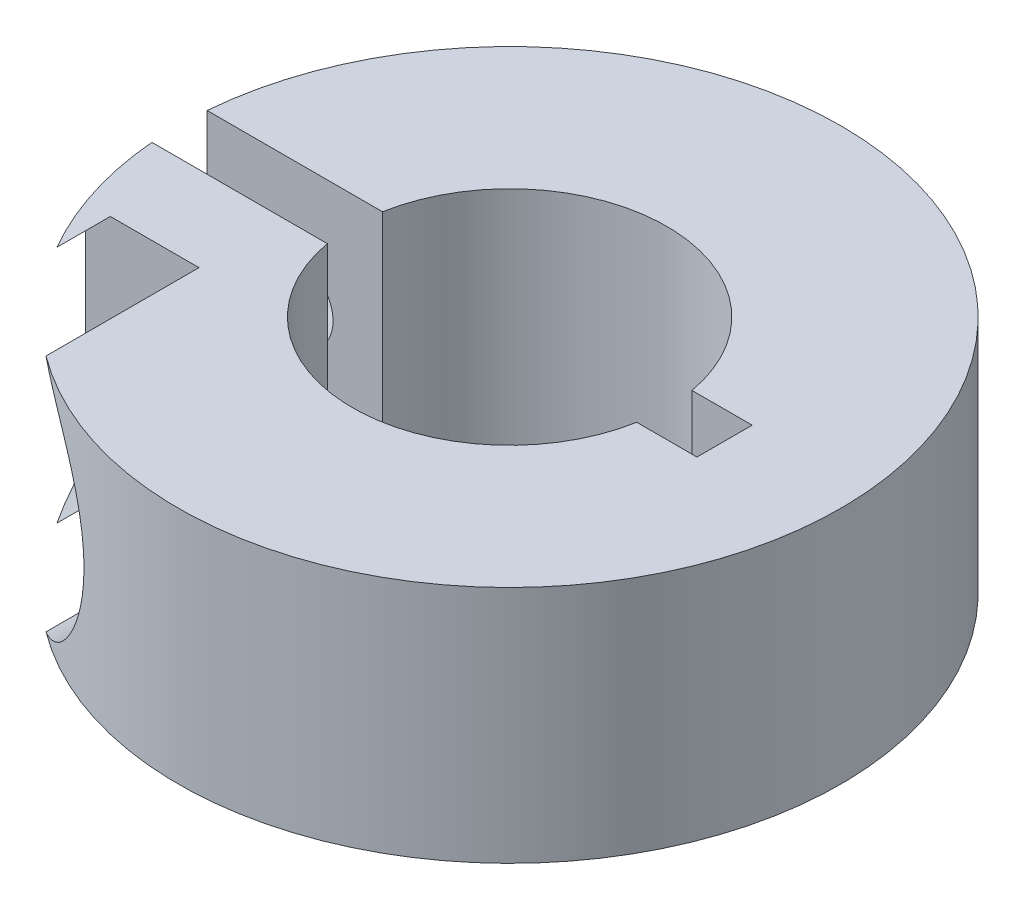
from build123d import *

# Parameters (mm, degrees)
SKETCH1_R               = 9.906
BOSS_EXTRUDE1_DEPTH     = 7.14375
SKETCH2_R               = 4.699
CUT_EXTRUDE1_DEPTH      = 8.14375
SKETCH5_W               = 1.651
SKETCH5_H               = 13.498105676
CUT_EXTRUDE3_DEPTH      = 16.3322
SKETCH6_R               = 1.143
CUT_EXTRUDE4_DEPTH      = 11.7315
CUT_EXTRUDE4_DEPTH_BACK = 10.0805
SKETCH8_R               = 3.81
CUT_EXTRUDE5_DEPTH      = 16.3322


with BuildPart() as part:
    # Sketch1 → Boss-Extrude1 (new body)
    with BuildSketch(Plane(origin=(0, 0, 0), x_dir=(1, 0, 0), z_dir=(0, 1, 0))):
        Circle(SKETCH1_R)
    extrude(amount=BOSS_EXTRUDE1_DEPTH)

    # Sketch2 → Cut-Extrude1 (cut, through all)
    with BuildSketch(Plane(origin=(0, 0, 0), x_dir=(-1, 0, 0), z_dir=(0, -1, 0))):
        Circle(SKETCH2_R)
    extrude(amount=-CUT_EXTRUDE1_DEPTH, mode=Mode.SUBTRACT)

    # Sketch5 → Cut-Extrude3 (cut)
    with BuildSketch(Plane.ZY.offset(9.906)):
        with Locations((0, 5.193192543)):
            Rectangle(SKETCH5_W, SKETCH5_H)
    extrude(amount=-CUT_EXTRUDE3_DEPTH, mode=Mode.SUBTRACT)

    # Sketch6 → Cut-Extrude4 (cut, two sides)
    with BuildSketch(Plane.XY.offset(-0.8255)) as cut_extrude4_sk:
        with Locations((-7.248732927, 3.571875)):
            Circle(SKETCH6_R)
    extrude(amount=CUT_EXTRUDE4_DEPTH, mode=Mode.SUBTRACT)
    extrude(cut_extrude4_sk.sketch, amount=-CUT_EXTRUDE4_DEPTH_BACK, mode=Mode.SUBTRACT)

    # Sketch8 → Cut-Extrude5 (cut)
    with BuildSketch(Plane(origin=(0, 0, 3.3655), x_dir=(-1, 0, 0), z_dir=(0, 0, -1))):
        with Locations((7.248732927, 3.571875)):
            Circle(SKETCH8_R)
    extrude(amount=-CUT_EXTRUDE5_DEPTH, mode=Mode.SUBTRACT)


solid = part.part
